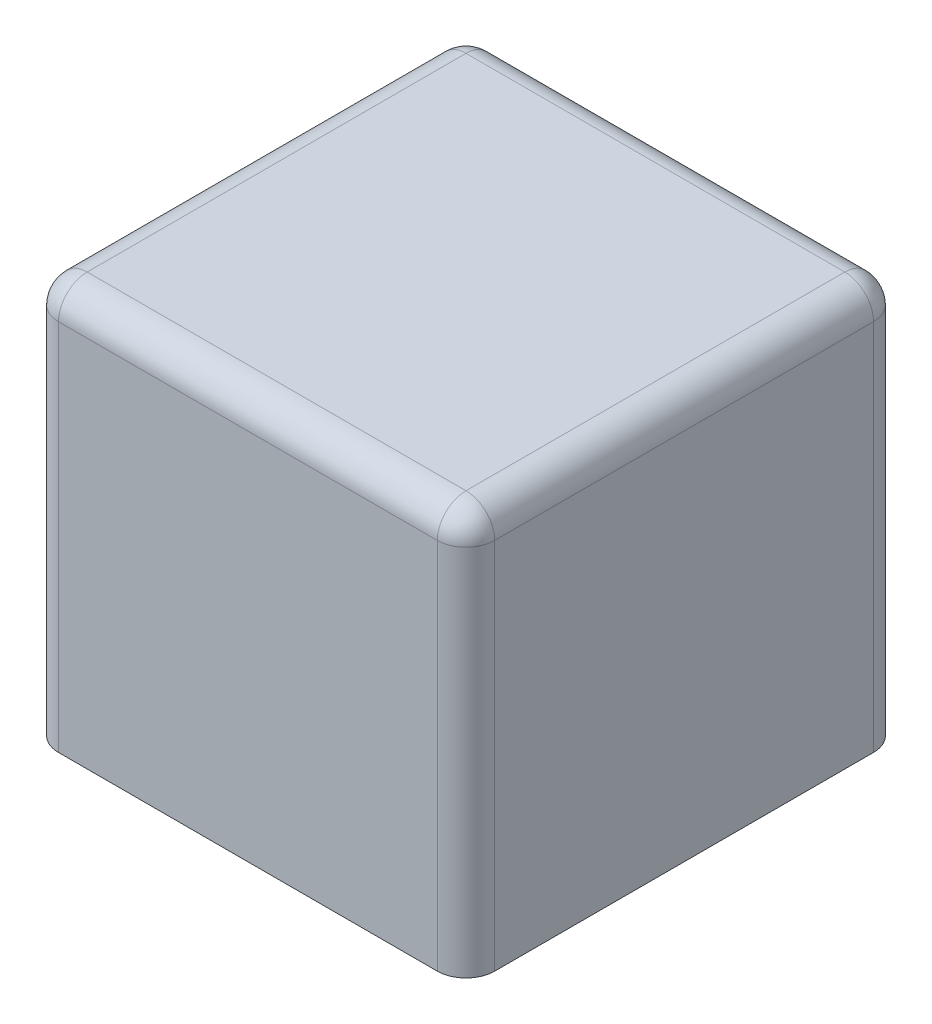
from build123d import *

# Parameters (mm, degrees)
SKETCH1_W           = 7.6
SKETCH1_H           = 7.6
BOSS_EXTRUDE1_DEPTH = 7
SKETCH2_W           = 6.6
SKETCH2_H           = 6.6
CUT_EXTRUDE1_DEPTH  = 6.5
FILLET2_R           = 0.5


with BuildPart() as part:
    # Sketch1 → Boss-Extrude1 (new body)
    with BuildSketch(Plane(origin=(0, 0, 0), x_dir=(1, 0, 0), z_dir=(0, 1, 0))):
        Rectangle(SKETCH1_W, SKETCH1_H)
    extrude(amount=BOSS_EXTRUDE1_DEPTH)

    # Sketch2 → Cut-Extrude1 (cut)
    with BuildSketch(Plane.XZ):
        Rectangle(SKETCH2_W, SKETCH2_H)
    extrude(amount=-CUT_EXTRUDE1_DEPTH, mode=Mode.SUBTRACT)

    # Fillet2
    fillet2_edges = [part.edges().sort_by_distance(p)[0] for p in [
        (-3.8, 7, 0),
        (0, 7, 3.8),
        (0, 6.5, 3.3),
        (-3.3, 3.25, 3.3),
        (3.3, 6.5, 0),
        (3.3, 3.25, 3.3),
        (0, 6.5, -3.3),
        (3.3, 3.25, -3.3),
        (-3.3, 6.5, 0),
        (-3.3, 3.25, -3.3),
        (3.8, 7, 0),
        (0, 7, -3.8),
        (3.8, 3.5, 3.8),
        (-3.8, 3.5, 3.8),
        (-3.8, 3.5, -3.8),
        (3.8, 3.5, -3.8),
    ]]
    fillet(fillet2_edges, radius=FILLET2_R)


solid = part.part
